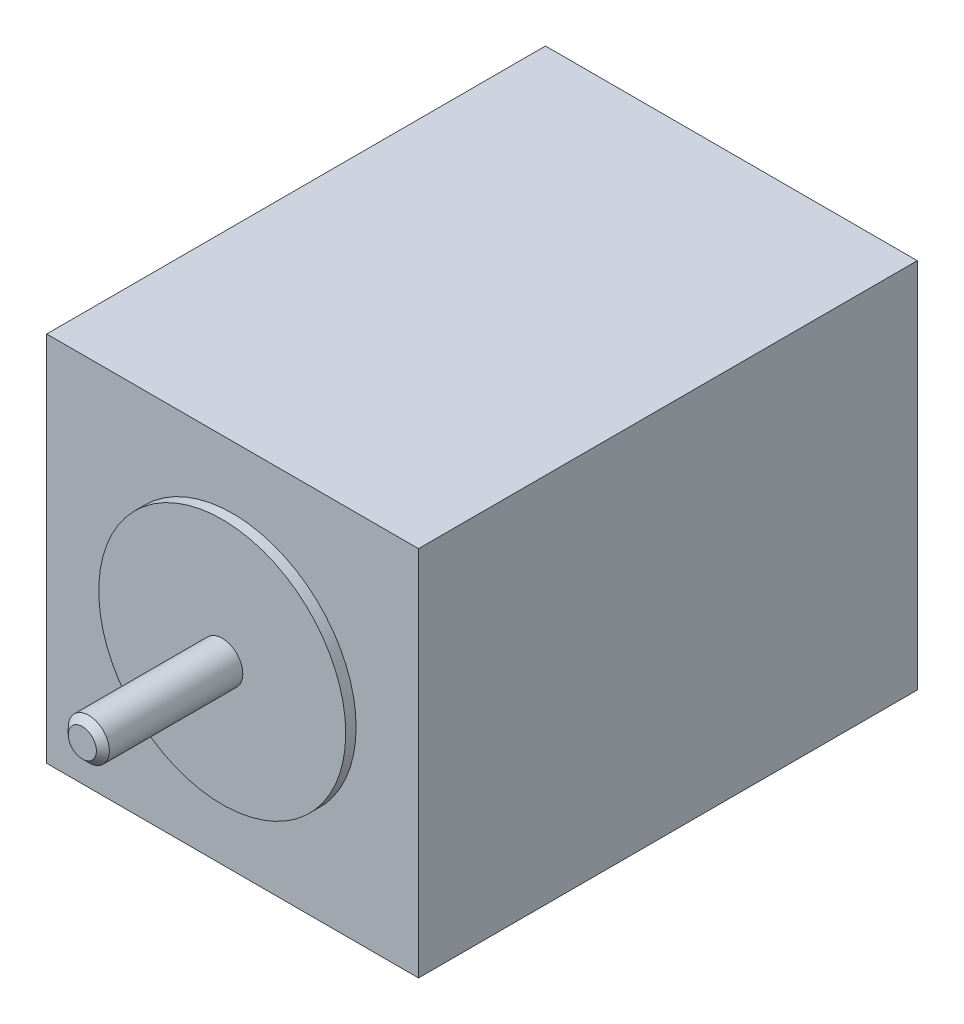
from build123d import *

# Parameters (mm, degrees)
SKIZZE1_W                       = 57.4
SKIZZE1_H                       = 57.4
AUFSATZ_LINEAR_AUSTRAGEN1_DEPTH = 77
SKIZZE2_R                       = 19.065
AUFSATZ_LINEAR_AUSTRAGEN2_DEPTH = 1.6
SKIZZE3_R                       = 3.175
AUFSATZ_LINEAR_AUSTRAGEN3_DEPTH = 21.6
FASE1_SIZE                      = 1


with BuildPart() as part:
    # Skizze1 → Aufsatz-Linear austragen1 (new body)
    with BuildSketch(Plane.XY):
        with Locations((28.7, 28.7)):
            Rectangle(SKIZZE1_W, SKIZZE1_H)
    extrude(amount=-AUFSATZ_LINEAR_AUSTRAGEN1_DEPTH)

    # Skizze2 → Aufsatz-Linear austragen2 (add)
    with BuildSketch(Plane.XY):
        with Locations((28.7, 28.7)):
            Circle(SKIZZE2_R)
    extrude(amount=AUFSATZ_LINEAR_AUSTRAGEN2_DEPTH)

    # Skizze3 → Aufsatz-Linear austragen3 (add)
    with BuildSketch(Plane.XY.offset(1.6)):
        with Locations((28.7, 28.7)):
            Circle(SKIZZE3_R)
    extrude(amount=AUFSATZ_LINEAR_AUSTRAGEN3_DEPTH)

    # Fase1
    fase1_edges = [part.edges().sort_by_distance(p)[0] for p in [
        (25.525, 28.7, 23.2),
    ]]
    chamfer(fase1_edges, length=FASE1_SIZE)


solid = part.part
